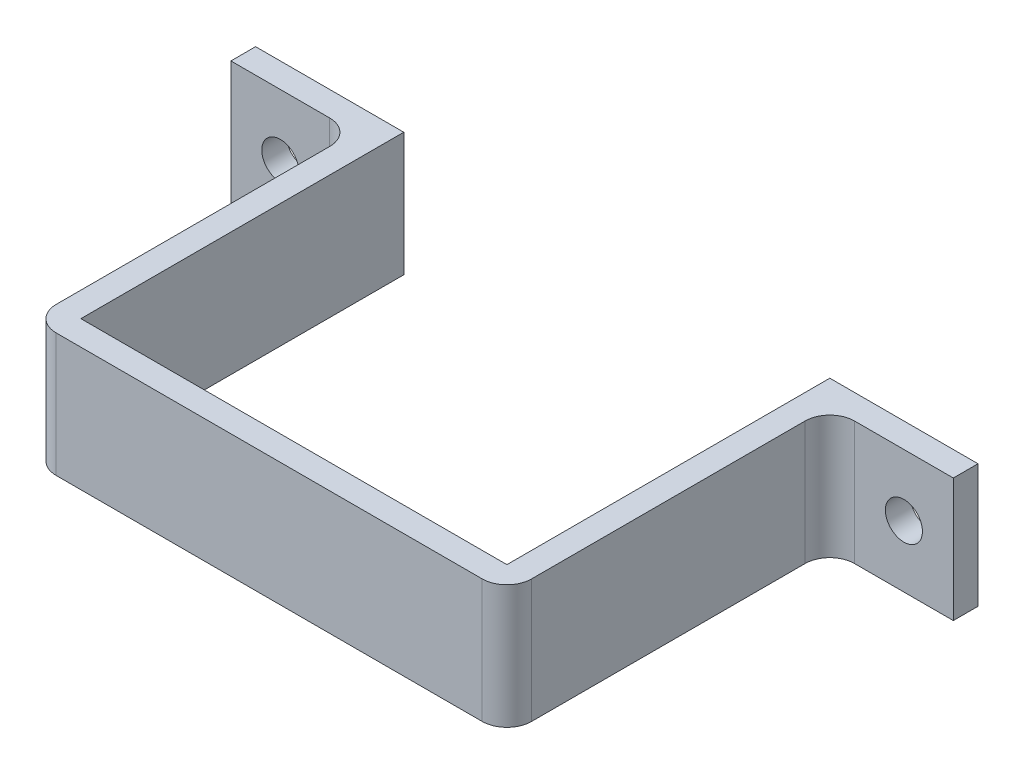
from build123d import *

# Parameters (mm, degrees)
BOSS_EXTRUDE1_START = 0.15
SKETCH1_W           = 30
SKETCH1_H           = 10
SKETCH1_W_2         = 2.25
BOSS_EXTRUDE1_DEPTH = 2
SKETCH2_W           = 2
SKETCH2_H           = 10
BOSS_EXTRUDE2_DEPTH = 28.15
SKETCH3_W           = 2
SKETCH3_H           = 10
BOSS_EXTRUDE3_DEPTH = 10
FILLET1_R           = 2
CUT_EXTRUDE1_START  = -2
SKETCH4_R           = 1.5
CUT_EXTRUDE1_DEPTH  = 29.15


with BuildPart() as part:
    # Sketch1 → Boss-Extrude1 (new body)
    with BuildSketch(Plane.XY.offset(BOSS_EXTRUDE1_START)):
        with Locations((0, 5.545087163)):
            Rectangle(SKETCH1_W, SKETCH1_H)
        with Locations((16.125, 5.545087163)):
            Rectangle(SKETCH1_W_2, SKETCH1_H)
        with Locations((-16.125, 5.545087163)):
            Rectangle(SKETCH1_W_2, SKETCH1_H)
    extrude(amount=BOSS_EXTRUDE1_DEPTH)

    # Sketch2 → Boss-Extrude2 (add)
    with BuildSketch(Plane.XY.offset(2.15)):
        with Locations((18.25, 5.545087163)):
            Rectangle(SKETCH2_W, SKETCH2_H)
        with Locations((-18.25, 5.545087163)):
            Rectangle(SKETCH2_W, SKETCH2_H)
    extrude(amount=-BOSS_EXTRUDE2_DEPTH)

    # Sketch3 → Boss-Extrude3 (add)
    with BuildSketch(Plane.ZY.offset(19.25)):
        with Locations((-25, 5.545087163)):
            Rectangle(SKETCH3_W, SKETCH3_H)
    boss_extrude3 = extrude(amount=BOSS_EXTRUDE3_DEPTH)

    # Mirror1: Boss-Extrude3 across plane
    add(boss_extrude3.mirror(Plane(origin=(0, 0, 0), x_dir=(0, 0, 1), z_dir=(1, 0, 0))))

    # Fillet1
    fillet1_edges = [part.edges().sort_by_distance(p)[0] for p in [
        (19.25, 5.545087163, 2.15),
        (-19.25, 5.545087163, 2.15),
        (-19.25, 5.545087163, -24),
        (19.25, 5.545087163, -24),
    ]]
    fillet(fillet1_edges, radius=FILLET1_R)

    # Sketch4 → Cut-Extrude1 (cut)
    with BuildSketch(Plane.XY.offset(-24).offset(CUT_EXTRUDE1_START)):
        with Locations((-25.25, 5.545087163)):
            Circle(SKETCH4_R)
    cut_extrude1 = extrude(amount=CUT_EXTRUDE1_DEPTH, mode=Mode.SUBTRACT)

    # Mirror2: Cut-Extrude1 across plane
    add(cut_extrude1.mirror(Plane(origin=(0, 0, 0), x_dir=(0, 0, 1), z_dir=(1, 0, 0))), mode=Mode.SUBTRACT)


solid = part.part
